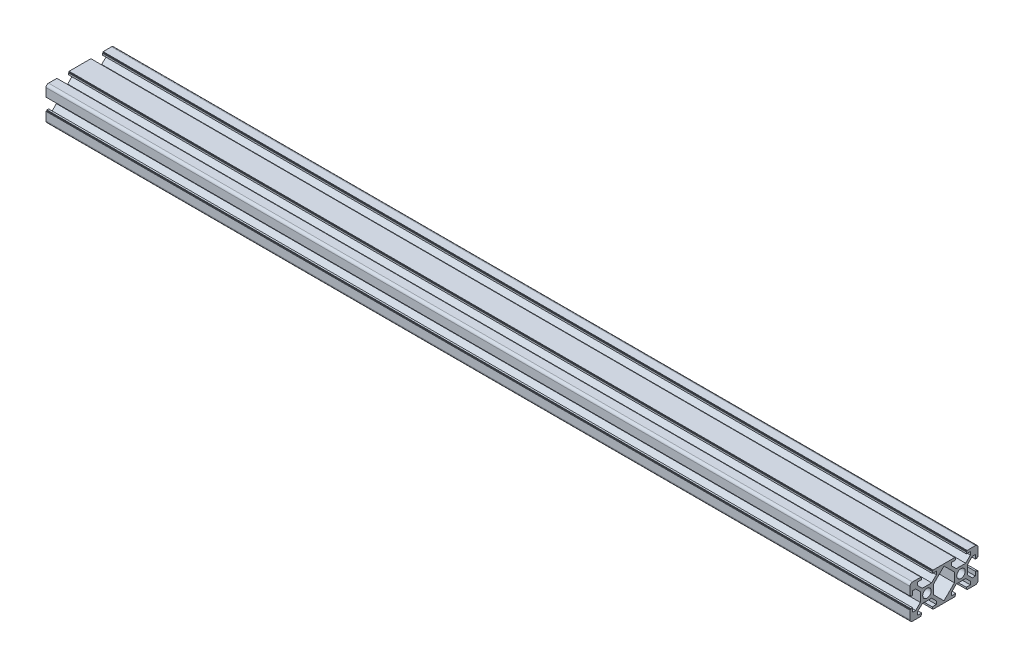
from build123d import *

# Parameters (mm, degrees)
SKETCH11_R               = 2.5
F_20_X_40_X_T1_5_1_DEPTH = 508


with BuildPart() as part:
    # Sketch11 → 铝型材 20 X 40 X T1.5(1) (new body)
    with BuildSketch(Plane.YZ):
        with BuildLine():
            Line((-3.6, 10), (-3.6, 9.5))
            Line((-3.6, 9.5), (-3.1, 9.5))
            Line((-3.1, 9.5), (-3.1, 8.5))
            Line((-3.1, 8.5), (-5.5, 8.5))
            Line((-5.5, 8.5), (-5.5, 6.65))
            Line((-5.5, 6.65), (-2.75, 3.9))
            Line((-2.75, 3.9), (2.75, 3.9))
            Line((2.75, 3.9), (5.5, 6.65))
            Line((5.5, 6.65), (5.5, 8.5))
            Line((5.5, 8.5), (3.1, 8.5))
            Line((3.1, 8.5), (3.1, 9.5))
            Line((3.1, 9.5), (3.6, 9.5))
            Line((3.6, 9.5), (3.6, 10))
            Line((3.6, 10), (8.5, 10))
            ThreePointArc((8.5, 10), (9.560660172, 9.560660172), (10, 8.5))
            Line((10, 8.5), (10, 3.6))
            Line((10, 3.6), (9.5, 3.6))
            Line((9.5, 3.6), (9.5, 3.1))
            Line((9.5, 3.1), (8.5, 3.1))
            Line((8.5, 3.1), (8.5, 5.5))
            Line((8.5, 5.5), (6.65, 5.5))
            Line((6.65, 5.5), (3.9, 2.75))
            Line((3.9, 2.75), (3.9, -2.75))
            Line((3.9, -2.75), (6.65, -5.5))
            Line((6.65, -5.5), (8.5, -5.5))
            Line((8.5, -5.5), (8.5, -3.1))
            Line((8.5, -3.1), (9.5, -3.1))
            Line((9.5, -3.1), (9.5, -3.6))
            Line((9.5, -3.6), (10, -3.6))
            Line((10, -3.6), (10, -16.4))
            Line((10, -16.4), (9.5, -16.4))
            Line((9.5, -16.4), (9.5, -16.9))
            Line((9.5, -16.9), (8.5, -16.9))
            Line((8.5, -16.9), (8.5, -14.5))
            Line((8.5, -14.5), (6.65, -14.5))
            Line((6.65, -14.5), (3.9, -17.25))
            Line((3.9, -17.25), (3.9, -22.75))
            Line((3.9, -22.75), (6.65, -25.5))
            Line((6.65, -25.5), (8.5, -25.5))
            Line((8.5, -25.5), (8.5, -23.1))
            Line((8.5, -23.1), (9.5, -23.1))
            Line((9.5, -23.1), (9.5, -23.6))
            Line((9.5, -23.6), (10, -23.6))
            Line((10, -23.6), (10, -28.5))
            ThreePointArc((10, -28.5), (9.560660172, -29.560660172), (8.5, -30))
            Line((8.5, -30), (3.6, -30))
            Line((3.6, -30), (3.6, -29.5))
            Line((3.6, -29.5), (3.1, -29.5))
            Line((3.1, -29.5), (3.1, -28.5))
            Line((3.1, -28.5), (5.5, -28.5))
            Line((5.5, -28.5), (5.5, -26.65))
            Line((5.5, -26.65), (2.75, -23.9))
            Line((2.75, -23.9), (-2.75, -23.9))
            Line((-2.75, -23.9), (-5.5, -26.65))
            Line((-5.5, -26.65), (-5.5, -28.5))
            Line((-5.5, -28.5), (-3.1, -28.5))
            Line((-3.1, -28.5), (-3.1, -29.5))
            Line((-3.1, -29.5), (-3.6, -29.5))
            Line((-3.6, -29.5), (-3.6, -30))
            Line((-3.6, -30), (-8.5, -30))
            ThreePointArc((-8.5, -30), (-9.560660172, -29.560660172), (-10, -28.5))
            Line((-10, -28.5), (-10, -23.6))
            Line((-10, -23.6), (-9.5, -23.6))
            Line((-9.5, -23.6), (-9.5, -23.1))
            Line((-9.5, -23.1), (-8.5, -23.1))
            Line((-8.5, -23.1), (-8.5, -25.5))
            Line((-8.5, -25.5), (-6.65, -25.5))
            Line((-6.65, -25.5), (-3.9, -22.75))
            Line((-3.9, -22.75), (-3.9, -17.25))
            Line((-3.9, -17.25), (-6.65, -14.5))
            Line((-6.65, -14.5), (-8.5, -14.5))
            Line((-8.5, -14.5), (-8.5, -16.9))
            Line((-8.5, -16.9), (-9.5, -16.9))
            Line((-9.5, -16.9), (-9.5, -16.4))
            Line((-9.5, -16.4), (-10, -16.4))
            Line((-10, -16.4), (-10, -3.6))
            Line((-10, -3.6), (-9.5, -3.6))
            Line((-9.5, -3.6), (-9.5, -3.1))
            Line((-9.5, -3.1), (-8.5, -3.1))
            Line((-8.5, -3.1), (-8.5, -5.5))
            Line((-8.5, -5.5), (-6.65, -5.5))
            Line((-6.65, -5.5), (-3.9, -2.75))
            Line((-3.9, -2.75), (-3.9, 2.75))
            Line((-3.9, 2.75), (-6.65, 5.5))
            Line((-6.65, 5.5), (-8.5, 5.5))
            Line((-8.5, 5.5), (-8.5, 3.1))
            Line((-8.5, 3.1), (-9.5, 3.1))
            Line((-9.5, 3.1), (-9.5, 3.6))
            Line((-9.5, 3.6), (-10, 3.6))
            Line((-10, 3.6), (-10, 8.5))
            ThreePointArc((-10, 8.5), (-9.560660172, 9.560660172), (-8.5, 10))
            Line((-8.5, 10), (-3.6, 10))
        make_face()
        Circle(SKETCH11_R, mode=Mode.SUBTRACT)
        with Locations((0, -20)):
            Circle(SKETCH11_R, mode=Mode.SUBTRACT)
        Polygon((8.85, -10), (2.75, -3.9), (-2.75, -3.9), (-8.85, -10), (-2.75, -16.1), (2.75, -16.1), align=None, mode=Mode.SUBTRACT)
    extrude(amount=F_20_X_40_X_T1_5_1_DEPTH)


solid = part.part
